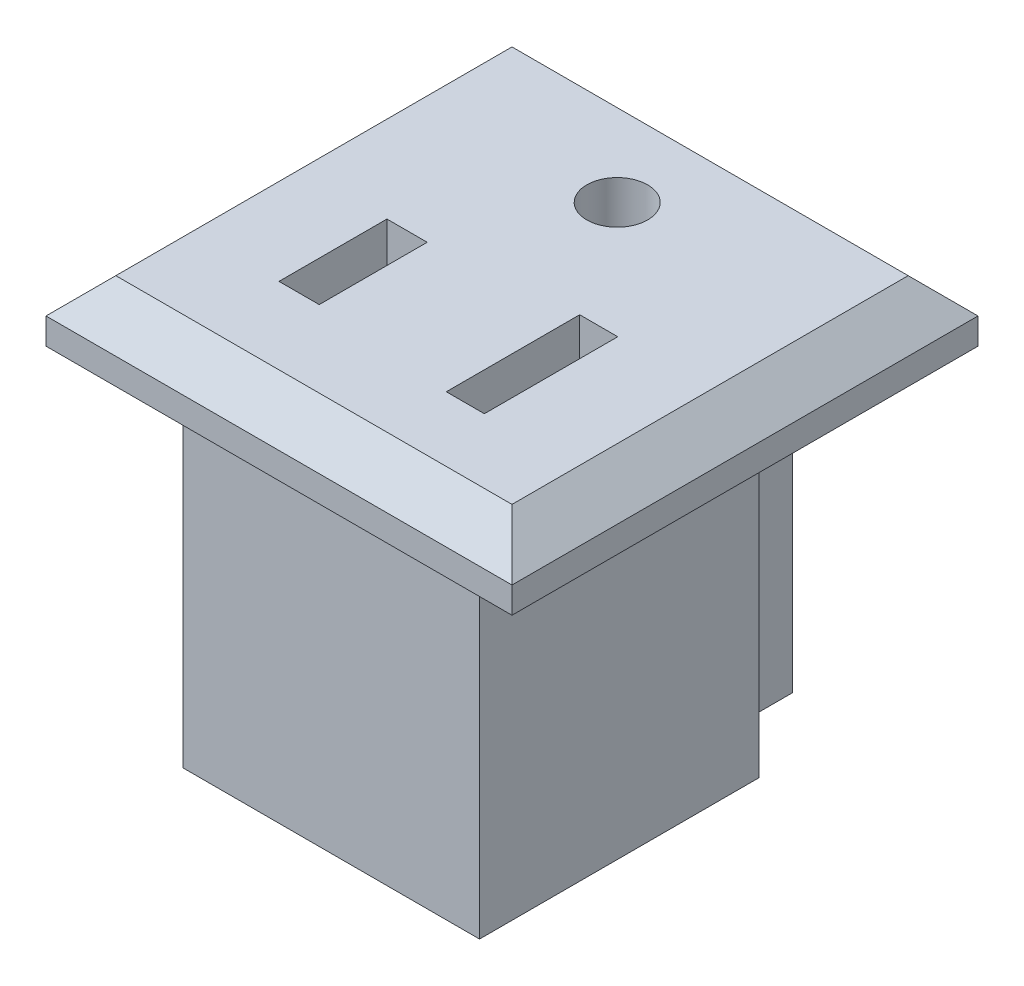
from build123d import *

# Parameters (mm, degrees)
SKETCH1_W           = 26.7
SKETCH1_H           = 26.7
BOSS_EXTRUDE1_DEPTH = 3.5
CHAMFER1_SIZE       = 2
SKETCH2_W           = 17
SKETCH2_H           = 16
BOSS_EXTRUDE2_DEPTH = 20
SKETCH3_W           = 9.899254973
SKETCH3_H           = 5.2
BOSS_EXTRUDE3_DEPTH = 20
SKETCH4_R           = 1.743878626
SKETCH4_W           = 2.182084489
SKETCH4_H           = 7.64251661
SKETCH4_W_2         = 2.305747791
SKETCH4_H_2         = 6.186643656
CUT_EXTRUDE1_DEPTH  = 5


with BuildPart() as part:
    # Sketch1 → Boss-Extrude1 (new body)
    with BuildSketch(Plane(origin=(0, 0, 0), x_dir=(1, 0, 0), z_dir=(0, 1, 0))):
        with Locations((-4.331476998, 13.35)):
            Rectangle(SKETCH1_W, SKETCH1_H)
    extrude(amount=BOSS_EXTRUDE1_DEPTH)

    # Chamfer1
    chamfer1_edges = [part.edges().sort_by_distance(p)[0] for p in [
        (9.018523002, 3.5, -13.35),
        (-4.331476998, 3.5, -26.7),
        (-17.681476998, 3.5, -13.35),
        (-4.331476998, 3.5, 0),
    ]]
    chamfer(chamfer1_edges, length=CHAMFER1_SIZE)

    # Sketch2 → Boss-Extrude2 (add)
    with BuildSketch(Plane.XZ):
        with Locations((-4.341476998, -11)):
            Rectangle(SKETCH2_W, SKETCH2_H)
    extrude(amount=BOSS_EXTRUDE2_DEPTH)

    # Sketch3 → Boss-Extrude3 (add)
    with BuildSketch(Plane.XZ):
        with Locations((-4.047830724, -21.6)):
            Rectangle(SKETCH3_W, SKETCH3_H)
    extrude(amount=BOSS_EXTRUDE3_DEPTH)

    # Sketch4 → Cut-Extrude1 (cut)
    with BuildSketch(Plane(origin=(0, 3.5, 0), x_dir=(1, 0, 0), z_dir=(0, 1, 0))):
        with Locations((-4.952893076, 19.999076914)):
            Circle(SKETCH4_R)
        with Locations((0.638087746, 9.527693342)):
            Rectangle(SKETCH4_W, SKETCH4_H)
        with Locations((-9.570218526, 9.483654221)):
            Rectangle(SKETCH4_W_2, SKETCH4_H_2)
    extrude(amount=-CUT_EXTRUDE1_DEPTH, mode=Mode.SUBTRACT)


solid = part.part
